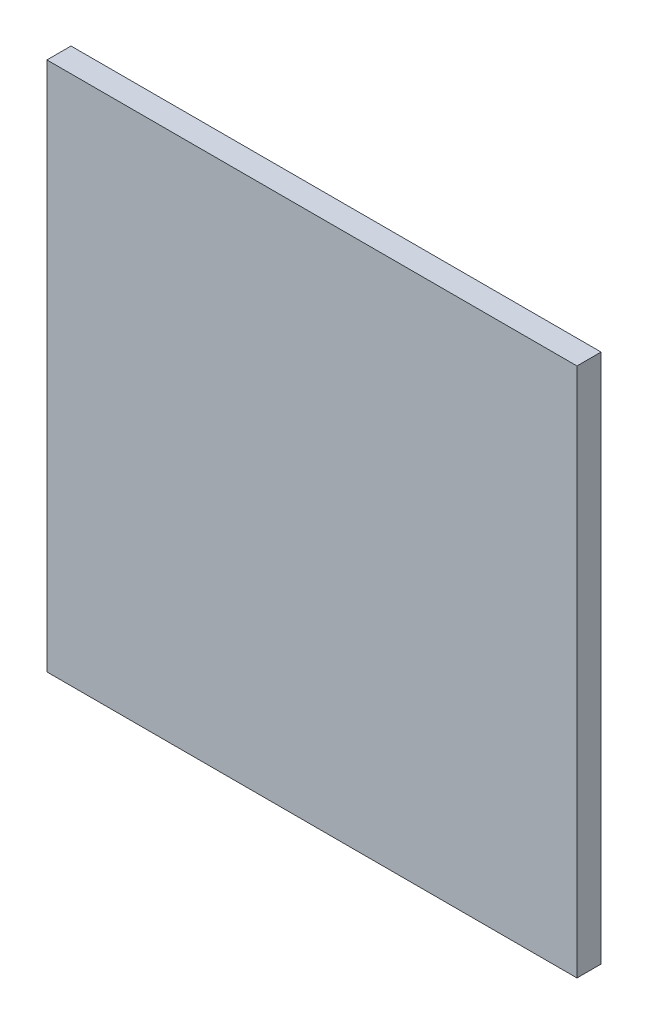
from build123d import *

# Parameters (mm, degrees)
SKETCH1_W           = 279.4
SKETCH1_H           = 279.4
BOSS_EXTRUDE1_DEPTH = 12.7


with BuildPart() as part:
    # Sketch1 → Boss-Extrude1 (new body)
    with BuildSketch(Plane.XY):
        with Locations((139.7, 139.7)):
            Rectangle(SKETCH1_W, SKETCH1_H)
    extrude(amount=BOSS_EXTRUDE1_DEPTH)


solid = part.part
